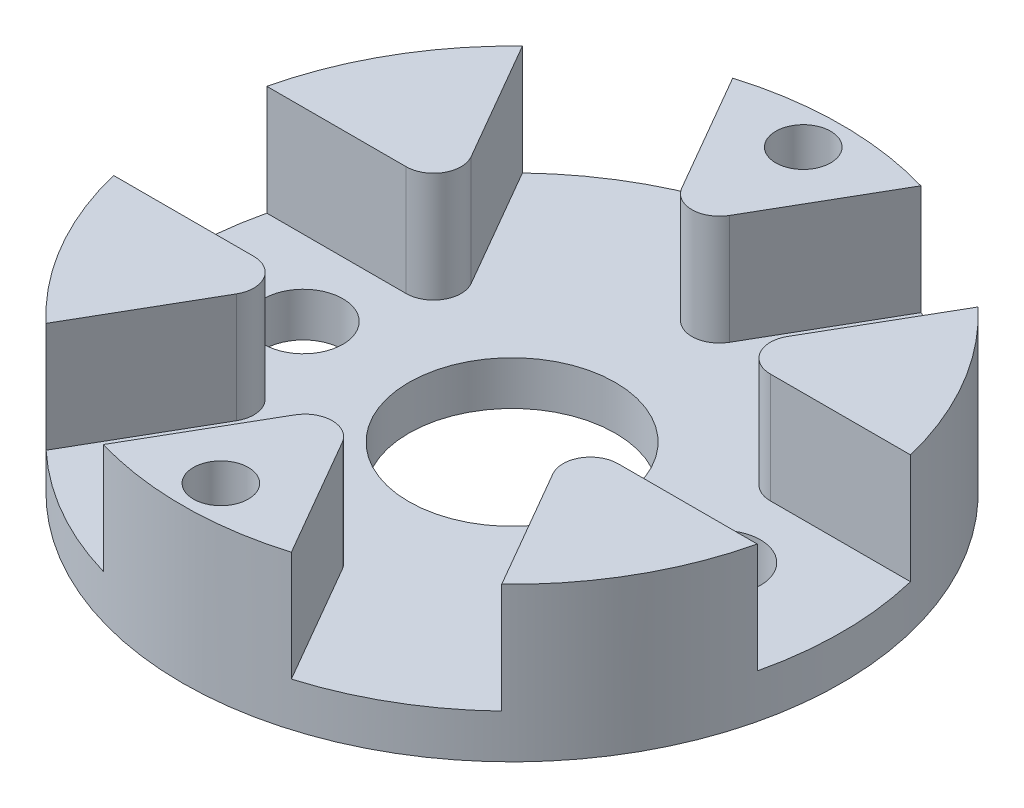
from build123d import *

# Parameters (mm, degrees)
SKETCH1_R         = 15
SKETCH1_R_2       = 4.7
BASE_DEPTH        = 2
TRIANGLES_DEPTH   = 5
FILLET1_R         = 1.25
WHEEL_HOLES_REACH = 4
SKETCH3_R         = 1.8
SKETCH4_R         = 1.25
HORN_HOLES_DEPTH  = 8


with BuildPart() as part:
    # Sketch1 → Base (new body)
    with BuildSketch(Plane(origin=(0, 0, 0), x_dir=(1, 0, 0), z_dir=(0, 1, 0))):
        Circle(SKETCH1_R)
        Circle(SKETCH1_R_2, mode=Mode.SUBTRACT)
    extrude(amount=BASE_DEPTH)

    # Sketch2 → Triangles (add)
    with BuildSketch(Plane(origin=(0, 2, 0), x_dir=(1, 0, 0), z_dir=(0, 1, 0))):
        with BuildLine():
            Line((6.028500388, 3.557693505), (14.571422537, 3.560006353))
            ThreePointArc((14.571422537, 3.560006353), (12.959336441, 7.553515672), (10.279001399, 10.924382373))
            Line((10.279001399, 10.924382373), (6.028500388, 3.557693505))
        make_face()
        with BuildLine():
            Line((-0.066802761, 6.999681235), (4.202655329, 14.399225263))
            ThreePointArc((4.202655329, 14.399225263), (-0.061868239, 14.99987241), (-4.321291956, 14.364067524))
            Line((-4.321291956, 14.364067524), (-0.066802761, 6.999681235))
        make_face()
        with BuildLine():
            Line((6.095303148, -3.44198773), (10.368767208, -10.83921891))
            ThreePointArc((10.368767208, -10.83921891), (13.02120468, -7.446356739), (14.600293355, -3.439685151))
            Line((14.600293355, -3.439685151), (6.095303148, -3.44198773))
        make_face()
        with BuildLine():
            Line((0.066802761, -6.999681235), (-4.202655329, -14.399225263))
            ThreePointArc((-4.202655329, -14.399225263), (0.061868239, -14.99987241), (4.321291956, -14.364067524))
            Line((4.321291956, -14.364067524), (0.066802761, -6.999681235))
        make_face()
        with BuildLine():
            Line((-6.028500388, -3.557693505), (-14.571422537, -3.560006353))
            ThreePointArc((-14.571422537, -3.560006353), (-12.959336441, -7.553515672), (-10.279001399, -10.924382373))
            Line((-10.279001399, -10.924382373), (-6.028500388, -3.557693505))
        make_face()
        with BuildLine():
            Line((-6.095303148, 3.44198773), (-10.368767208, 10.83921891))
            ThreePointArc((-10.368767208, 10.83921891), (-13.02120468, 7.446356739), (-14.600293355, 3.439685151))
            Line((-14.600293355, 3.439685151), (-6.095303148, 3.44198773))
        make_face()
    extrude(amount=TRIANGLES_DEPTH)

    # Fillet1
    fillet1_edges = [part.edges().sort_by_distance(p)[0] for p in [
        (6.095303148, 4.5, 3.44198773),
        (0.066802761, 4.5, 6.999681235),
        (-6.028500388, 4.5, 3.557693505),
        (-6.095303148, 4.5, -3.44198773),
        (6.028500388, 4.5, -3.557693505),
        (-0.066802761, 4.5, -6.999681235),
    ]]
    fillet(fillet1_edges, radius=FILLET1_R)

    # Sketch3 → Wheel Holes (cut, up to next)
    with BuildSketch(Plane(origin=(0, 2, 0), x_dir=(1, 0, 0), z_dir=(0, 1, 0)), mode=Mode.PRIVATE) as wheel_holes_sk1:
        with Locations((-9.5, 0)):
            Circle(SKETCH3_R)
    wheel_holes_tool1 = extrude(wheel_holes_sk1.sketch, amount=-WHEEL_HOLES_REACH, mode=Mode.PRIVATE) & part.part
    add(wheel_holes_tool1.solids().sort_by_distance((-9.5, 2, 0))[0], mode=Mode.SUBTRACT)
    # Sketch3 → Wheel Holes (cut, up to next)
    with BuildSketch(Plane(origin=(0, 2, 0), x_dir=(1, 0, 0), z_dir=(0, 1, 0)), mode=Mode.PRIVATE) as wheel_holes_sk2:
        with Locations((9.5, 0)):
            Circle(SKETCH3_R)
    wheel_holes_tool2 = extrude(wheel_holes_sk2.sketch, amount=-WHEEL_HOLES_REACH, mode=Mode.PRIVATE) & part.part
    add(wheel_holes_tool2.solids().sort_by_distance((9.5, 2, 0))[0], mode=Mode.SUBTRACT)

    # Sketch4 → Horn Holes (cut, through all)
    with BuildSketch(Plane(origin=(0, 7, 0), x_dir=(1, 0, 0), z_dir=(0, 1, 0))):
        with Locations((0, 13.25)):
            Circle(SKETCH4_R)
        with Locations((0, -13.25)):
            Circle(SKETCH4_R)
    extrude(amount=-HORN_HOLES_DEPTH, mode=Mode.SUBTRACT)


solid = part.part
